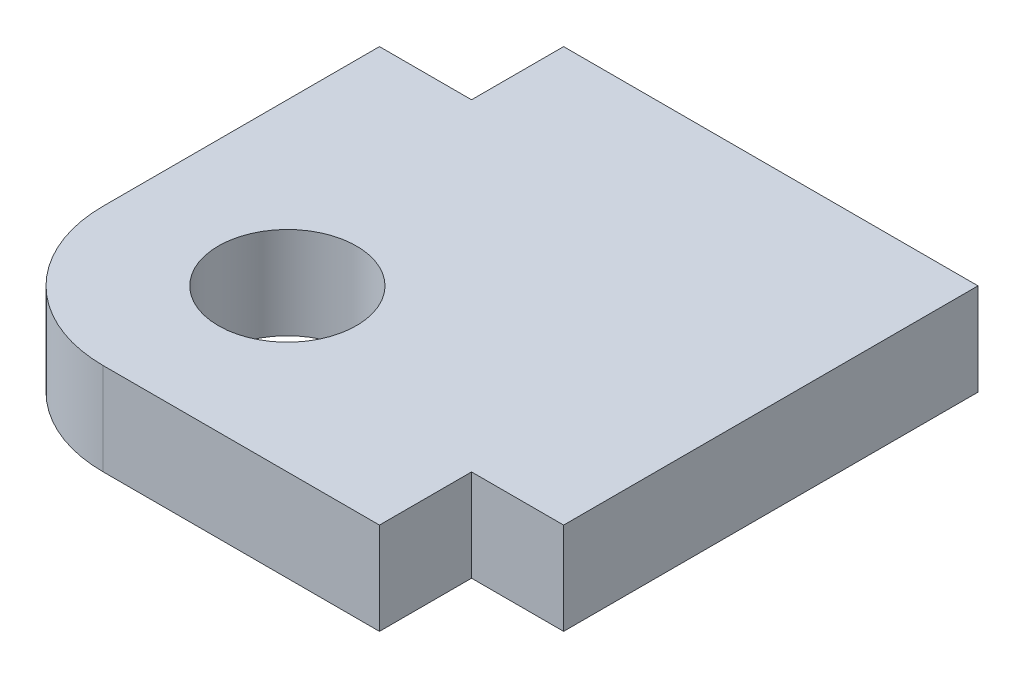
from build123d import *

# Parameters (mm, degrees)
SKETCH1_R           = 1.5
BOSS_EXTRUDE1_DEPTH = 2


with BuildPart() as part:
    # Sketch1 → Boss-Extrude1 (new body)
    with BuildSketch(Plane(origin=(0, 0, 0), x_dir=(1, 0, 0), z_dir=(0, 1, 0))):
        with BuildLine():
            Line((6.37772525, 5.938862625), (-2.62227475, 5.938862625))
            Line((-2.62227475, 5.938862625), (-2.62227475, 3.938862625))
            Line((-2.62227475, 3.938862625), (-4.62227475, 3.938862625))
            Line((-4.62227475, 3.938862625), (-4.62227475, -2.061137375))
            ThreePointArc((-4.62227475, -2.061137375), (-3.743595093, -4.182457719), (-1.62227475, -5.061137375))
            Line((-1.62227475, -5.061137375), (4.37772525, -5.061137375))
            Line((4.37772525, -5.061137375), (4.37772525, -3.061137375))
            Line((4.37772525, -3.061137375), (6.37772525, -3.061137375))
            Line((6.37772525, -3.061137375), (6.37772525, 5.938862625))
        make_face()
        with Locations((-1.12227475, -1.561137375)):
            Circle(SKETCH1_R, mode=Mode.SUBTRACT)
    extrude(amount=BOSS_EXTRUDE1_DEPTH)


solid = part.part
